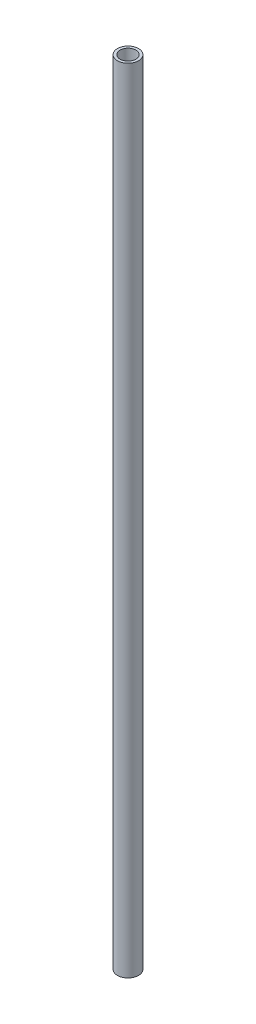
from build123d import *

# Parameters (mm, degrees)
SKETCH_1_R      = 4
SKETCH_1_R_2    = 3
EXTRUDE_1_DEPTH = 300


with BuildPart() as part:
    # Эскиз1 → Бобышка-Вытянуть1 (new body)
    with BuildSketch(Plane(origin=(0, 0, 0), x_dir=(1, 0, 0), z_dir=(0, 1, 0))):
        Circle(SKETCH_1_R)
        Circle(SKETCH_1_R_2, mode=Mode.SUBTRACT)
    extrude(amount=EXTRUDE_1_DEPTH)


solid = part.part
